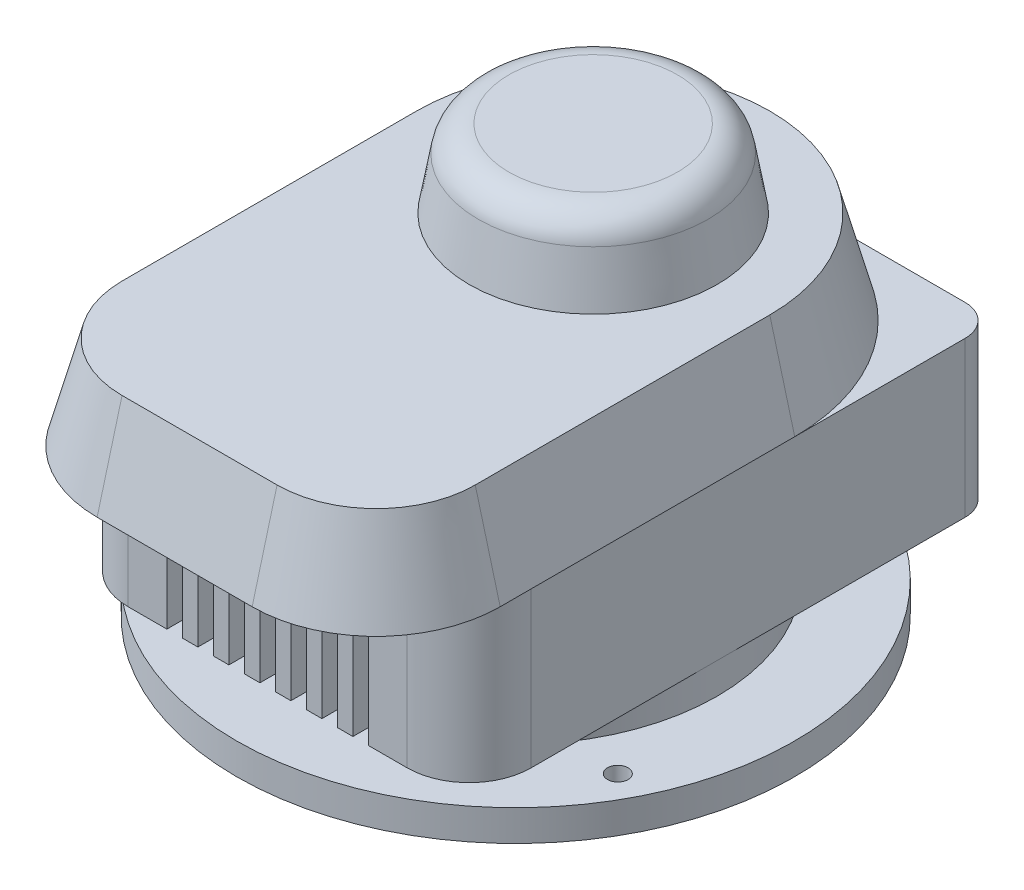
from build123d import *

# Parameters (mm, degrees)
SKETCH1_R                   = 88.9
BASE_DEPTH                  = 12.7
SKETCH1_4_R                 = 114.3
SKETCH1_4_R_2               = 88.9
BOLT_BELT_DEPTH             = 12.7
F_3_8_24_TAPPED_HOLE1_D     = 8.4328
SKETCH21_R                  = 82.55
ENGINE_OFFSET_DEPTH         = 12.7
SKETCH20_W                  = 165.1
SKETCH20_H                  = 215.9
ENGINE_BLOCK_DEPTH          = 63.5
ENGINE_BLOCK_FILLET_FRONT_R = 25.4
ENGINE_BLOCK_FILLET_BACK_R  = 12.7
SKETCH22_W                  = 6.35
SKETCH22_H                  = 25.4
FINS_DEPTH                  = 63.5
FIN_LPATTERN1_COUNT         = 4
FIN_LPATTERN1_PITCH         = 12.7
FIN_LPATTERN1_COL_COUNT     = 4
FIN_LPATTERN1_COL_PITCH     = 12.7
SHROUD_DEPTH                = 38.1
SHROUD_TAPER                = 15
SKETCH24_R                  = 50.8
CORD_HOUSING_DEPTH          = 31.75
CORD_HOUSING_TAPER          = 10
CORD_HOUSING_FILLET_R       = 12.7
SKETCH25_R                  = 9.525
BOSS_EXTRUDE7_DEPTH         = 25.4


with BuildPart() as part:
    # Sketch1 → Base (new body)
    with BuildSketch(Plane(origin=(0, 0, 0), x_dir=(1, 0, 0), z_dir=(0, 1, 0))):
        with Locations(Location((0, 0, 0), (0, 0, 270))):  # turned: the seam where the file's is
            Circle(SKETCH1_R)
    extrude(amount=-BASE_DEPTH)

    # Sketch1_4 → Bolt Belt (add)
    with BuildSketch(Plane(origin=(0, 0, 0), x_dir=(1, 0, 0), z_dir=(0, 1, 0))):
        with Locations(Location((0, 0, 0), (0, 0, 270))):  # turned: the seam where the file's is
            Circle(SKETCH1_4_R)
        with Locations(Location((0, 0, 0), (0, 0, 270))):  # turned: the seam where the file's is
            Circle(SKETCH1_4_R_2, mode=Mode.SUBTRACT)
        with Locations(Location((0, 0, 0), (0, 0, 270))):  # turned: the seam where the file's is
            Circle(SKETCH1_4_R_2)
    extrude(amount=BOLT_BELT_DEPTH)

    # 3_8-24 Tapped Hole1 (through all)
    with Locations(Plane.XZ):
        with Locations((-70.63929059, 73.025), (89.644179842, 47.817162405), (-55.633966752, -85.014244356)):
            Hole(F_3_8_24_TAPPED_HOLE1_D / 2)

    # Sketch21 → Engine Offset (add)
    with BuildSketch(Plane(origin=(0, 12.7, 0), x_dir=(1, 0, 0), z_dir=(0, 1, 0))):
        with Locations(Location((0, 0, 0), (0, 0, 270))):  # turned: the seam where the file's is
            Circle(SKETCH21_R)
    extrude(amount=ENGINE_OFFSET_DEPTH)

    # Sketch20 → Engine Block (add)
    with BuildSketch(Plane(origin=(0, 25.4, 0), x_dir=(1, 0, 0), z_dir=(0, 1, 0))):
        with Locations((0, 6.35)):
            Rectangle(SKETCH20_W, SKETCH20_H)
    extrude(amount=ENGINE_BLOCK_DEPTH)

    # Engine Block Fillet Front
    engine_block_fillet_front_edges = [part.edges().sort_by_distance(p)[0] for p in [
        (-82.55, 57.15, 101.6),
        (82.55, 57.15, 101.6),
    ]]
    fillet(engine_block_fillet_front_edges, radius=ENGINE_BLOCK_FILLET_FRONT_R)

    # Engine Block Fillet Back
    engine_block_fillet_back_edges = [part.edges().sort_by_distance(p)[0] for p in [
        (-82.55, 57.15, -114.3),
        (82.55, 57.15, -114.3),
    ]]
    fillet(engine_block_fillet_back_edges, radius=ENGINE_BLOCK_FILLET_BACK_R)

    # Sketch22 → Fins (cut)
    with BuildSketch(Plane(origin=(0, 88.9, 0), x_dir=(1, 0, 0), z_dir=(0, 1, 0))):
        with Locations((0, -101.6)):
            Rectangle(SKETCH22_W, SKETCH22_H)
    fins = extrude(amount=-FINS_DEPTH, mode=Mode.SUBTRACT)

    # Fin LPattern1: Fins ×4
    with Locations(*[(i * FIN_LPATTERN1_PITCH, 0, 0) for i in range(1, FIN_LPATTERN1_COUNT)]):
        add(fins, mode=Mode.SUBTRACT)

    # Fin LPattern1 col: Fins ×4
    with Locations(*[(-i * FIN_LPATTERN1_COL_PITCH, 0, 0) for i in range(1, FIN_LPATTERN1_COL_COUNT)]):
        add(fins, mode=Mode.SUBTRACT)

    # Sketch23 → Shroud (add)
    with BuildSketch(Plane(origin=(0, 88.9, 0), x_dir=(1, 0, 0), z_dir=(0, 1, 0))):
        with BuildLine():
            ThreePointArc((82.55, 31.75), (0, 114.3), (-82.55, 31.75))
            Line((-82.55, 31.75), (-82.55, -88.9))
            ThreePointArc((-82.55, -88.9), (-67.671024484, -124.821024484), (-31.75, -139.7))
            Line((-31.75, -139.7), (31.75, -139.7))
            ThreePointArc((31.75, -139.7), (67.671024484, -124.821024484), (82.55, -88.9))
            Line((82.55, -88.9), (82.55, 31.75))
        make_face()
    extrude(amount=SHROUD_DEPTH, taper=SHROUD_TAPER)

    # Sketch24 → Cord Housing (add)
    with BuildSketch(Plane(origin=(0, 127, 0), x_dir=(1, 0, 0), z_dir=(0, 1, 0))):
        with Locations((0, 31.75)):
            Circle(SKETCH24_R)
    extrude(amount=CORD_HOUSING_DEPTH, taper=CORD_HOUSING_TAPER)

    # Cord Housing Fillet
    cord_housing_fillet_edges = [part.edges().sort_by_distance(p)[0] for p in [
        (-45.201618363, 158.75, -31.75),
    ]]
    fillet(cord_housing_fillet_edges, radius=CORD_HOUSING_FILLET_R)

    # Sketch25 → Boss-Extrude7 (add)
    with BuildSketch(Plane.XZ.offset(12.7)):
        with Locations(Location((0, 0, 0), (0, 0, 90))):  # turned: the seam where the file's is
            Circle(SKETCH25_R)
    extrude(amount=BOSS_EXTRUDE7_DEPTH)


solid = part.part
